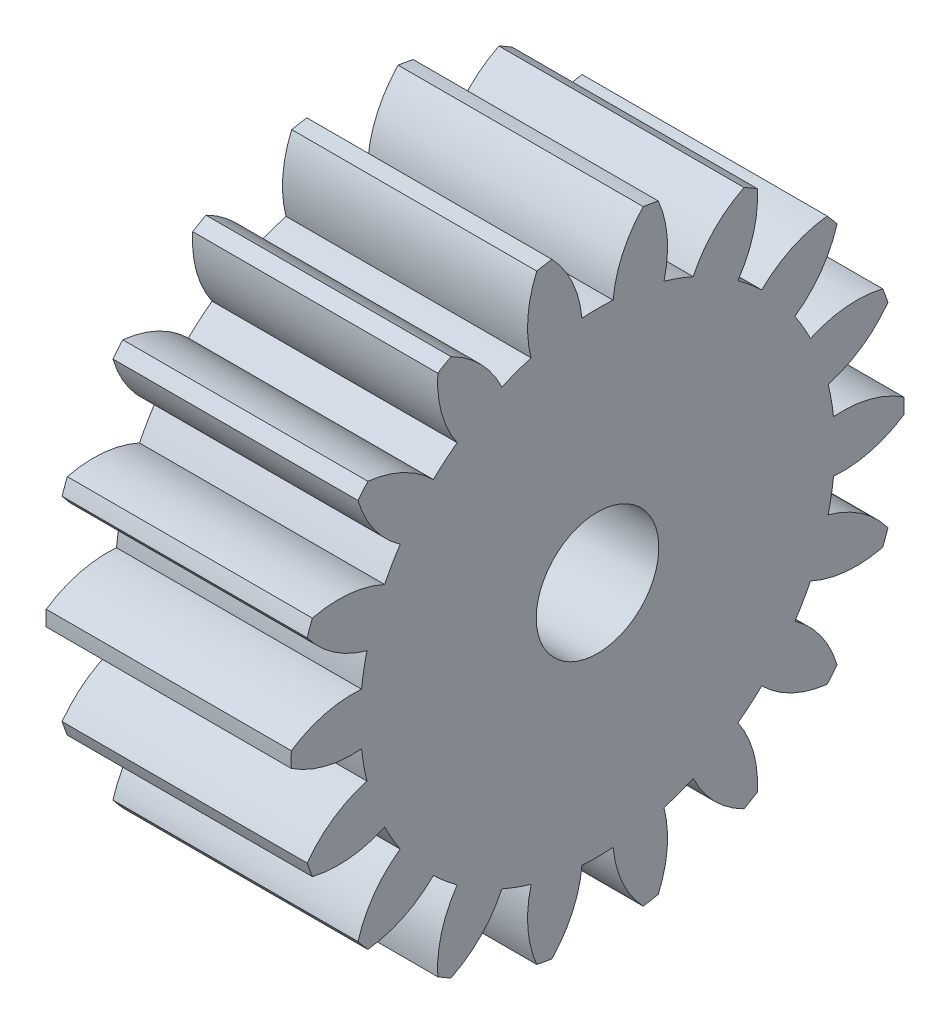
from build123d import *

# Parameters (mm, degrees)
BASPROSKE_W     = 50.8
BASPROSKE_H     = 63.5
TOOTHCUT_DEPTH  = 104.175287739
TEETHCUTS_COUNT = 18
BORSKE_R        = 12.7
BORE_DEPTH      = 50.8000508


with BuildPart() as part:
    # BasProSke → Base-Revolve (revolve)
    with BuildSketch(Plane(origin=(0, 0, 0), x_dir=(1, 0, 0), z_dir=(0, 1, 0)), mode=Mode.PRIVATE) as base_revolve_sk:
        with Locations((25.4, 31.75)):
            Rectangle(BASPROSKE_W, BASPROSKE_H)
    revolve(base_revolve_sk.sketch.rotate(Axis((-10, 0, 0), (1, 0, 0)), 180), axis=Axis((-10, 0, 0), (1, 0, 0)))

    # TooCutSke → ToothCut (cut, through all)
    with BuildSketch(Plane(origin=(0, 0, 0), x_dir=(0, 0, -1), z_dir=(1, 0, 0))):
        with BuildLine():
            ThreePointArc((3.223886101, 49.105516152), (0, 49.21123), (-3.223886101, 49.105516152))
            ThreePointArc((-3.223886101, 49.105516152), (-5.190584502, 56.49010796), (-9.481297068, 62.813863526))
            ThreePointArc((-9.481297068, 62.813863526), (0, 63.5254), (9.481297068, 62.813863526))
            ThreePointArc((9.481297068, 62.813863526), (5.190584502, 56.49010796), (3.223886101, 49.105516152))
        make_face()
    toothcut = extrude(amount=TOOTHCUT_DEPTH, mode=Mode.SUBTRACT)

    # TeethCuts: ToothCut ×18 about axis
    teethcuts_axis = Axis((0, 0, 0), (1, 0, 0))
    for i in range(1, TEETHCUTS_COUNT):
        add(toothcut.rotate(teethcuts_axis, i * 360 / TEETHCUTS_COUNT), mode=Mode.SUBTRACT)

    # BorSke → Bore (cut, symmetric)
    with BuildSketch(Plane(origin=(0, 0, 0), x_dir=(0, 0, -1), z_dir=(1, 0, 0))):
        with Locations(Location((0, 0, 0), (0, 0, 180))):
            Circle(BORSKE_R)
    extrude(amount=BORE_DEPTH, both=True, mode=Mode.SUBTRACT)


solid = part.part
